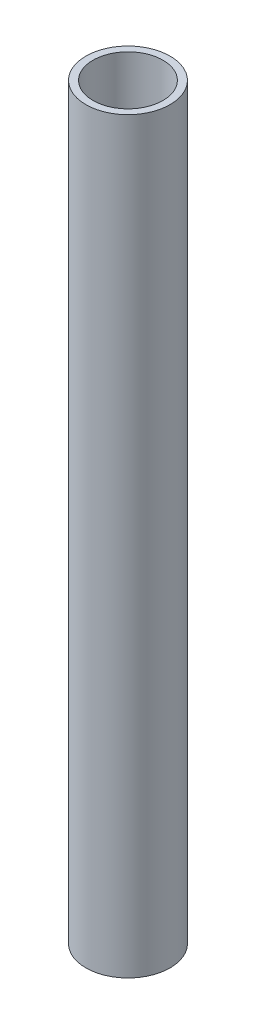
from build123d import *

# Parameters (mm, degrees)
SKETCH1_R           = 21.082
SKETCH1_R_2         = 17.526
BOSS_EXTRUDE1_DEPTH = 374.65


with BuildPart() as part:
    # Sketch1 → Boss-Extrude1 (new body)
    with BuildSketch(Plane(origin=(0, 0, 0), x_dir=(1, 0, 0), z_dir=(0, 1, 0))):
        Circle(SKETCH1_R)
        Circle(SKETCH1_R_2, mode=Mode.SUBTRACT)
    extrude(amount=BOSS_EXTRUDE1_DEPTH)


solid = part.part
